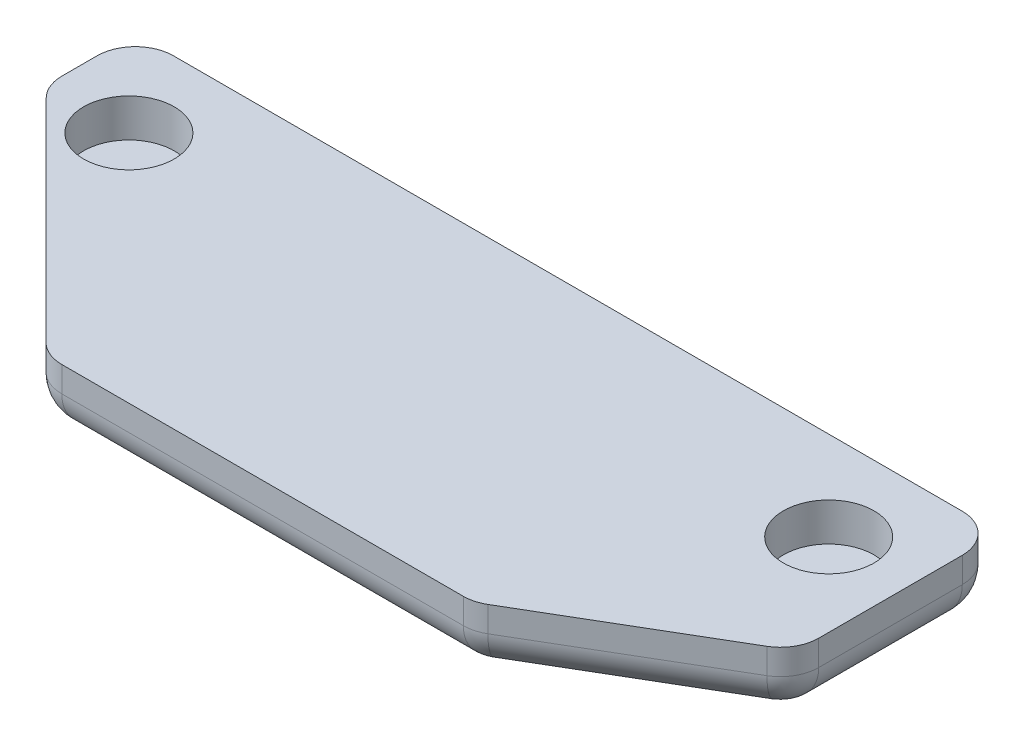
from build123d import *

# Parameters (mm, degrees)
BOSS_EXTRUDE1_DEPTH = 2.5
SKETCH4_R           = 1.78
CUT_EXTRUDE1_DEPTH  = 1.5
FILLET1_R           = 1.5


with BuildPart() as part:
    # Sketch2 → Boss-Extrude1 (new body)
    with BuildSketch(Plane(origin=(0, 0, 0), x_dir=(1, 0, 0), z_dir=(0, 1, 0))):
        Polygon((-21.216153836, 11.741903429), (-21.216153836, 8.241903429), (-12.024866066, -0.958096571), (4.783846164, -0.958096571), (12.783846164, 3.741903429), (12.783846164, 11.741903429), align=None)
    extrude(amount=BOSS_EXTRUDE1_DEPTH)

    # Sketch4 → Cut-Extrude1 (cut)
    with BuildSketch(Plane(origin=(0, 2.5, 0), x_dir=(1, 0, 0), z_dir=(0, 1, 0))):
        with Locations((-17.966153836, 8.241903429)):
            Circle(SKETCH4_R)
        with Locations((9.533846164, 8.241903429)):
            Circle(SKETCH4_R)
    extrude(amount=-CUT_EXTRUDE1_DEPTH, mode=Mode.SUBTRACT)

    # Fillet1
    fillet1_edges = [part.edges().sort_by_distance(p)[0] for p in [
        (12.783846164, 1.25, -11.741903429),
        (12.783846164, 1.25, -3.741903429),
        (4.783846164, 1.25, 0.958096571),
        (-12.024866066, 1.25, 0.958096571),
        (-21.216153836, 1.25, -8.241903429),
        (-21.216153836, 1.25, -11.741903429),
        (12.783846164, 0, -7.741903429),
        (8.783846164, 0, -1.391903429),
        (-3.620509951, 0, 0.958096571),
        (-16.620509951, 0, -3.641903429),
        (-21.216153836, 0, -9.991903429),
        (-4.216153836, 0, -11.741903429),
    ]]
    fillet(fillet1_edges, radius=FILLET1_R)


solid = part.part
